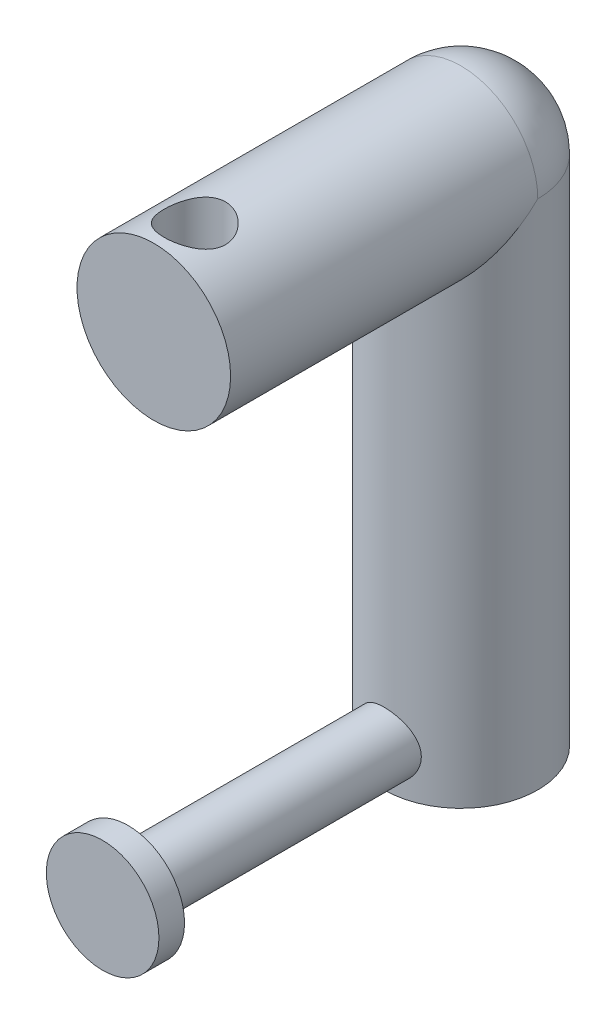
from build123d import *

# Parameters (mm, degrees)
SKETCH1_R                            = 15
BOSS_EXTRUDE1_DEPTH                  = 100
SKETCH2_R                            = 6
BOSS_EXTRUDE2_DEPTH                  = 50
BOSS_EXTRUDE2_DIRECTION_2_REACH      = 107.475
BOSS_EXTRUDE2_DIRECTION_2_END_RADIUS = 15
REVOLVE1_ANGLE                       = 180
SKETCH4_R                            = 15
BOSS_EXTRUDE3_DEPTH                  = 60
SKETCH5_R                            = 6
CUT_EXTRUDE1_DEPTH                   = 30
SKETCH6_R                            = 11
BOSS_EXTRUDE4_DEPTH                  = 5


with BuildPart() as part:
    # Sketch1 → Boss-Extrude1 (new body)
    with BuildSketch(Plane(origin=(0, 0, 0), x_dir=(1, 0, 0), z_dir=(0, 1, 0))):
        with Locations(Location((0, 0, 0), (0, 0, 270))):
            Circle(SKETCH1_R)
    extrude(amount=BOSS_EXTRUDE1_DEPTH)

    # Sketch3 → Revolve1 (revolve)
    with BuildSketch(Plane.XY):
        with BuildLine():
            Line((0, 100), (0, 115))
            ThreePointArc((0, 115), (-10.606601718, 110.606601718), (-15, 100))
            Line((-15, 100), (0, 100))
        make_face()
    revolve(axis=Axis((0, 100, 0), (0, -1, 0)), revolution_arc=REVOLVE1_ANGLE)

    # Sketch4 → Boss-Extrude3 (add)
    with BuildSketch(Plane.XY):
        with Locations((0, 100)):
            Circle(SKETCH4_R)
    extrude(amount=BOSS_EXTRUDE3_DEPTH)

    # Sketch5 → Cut-Extrude1 (cut)
    with BuildSketch(Plane(origin=(0, 115, 0), x_dir=(1, 0, 0), z_dir=(0, 1, 0))):
        with Locations(Location((0, -52, 0), (0, 0, 270))):
            Circle(SKETCH5_R)
    extrude(amount=-CUT_EXTRUDE1_DEPTH, mode=Mode.SUBTRACT)


with BuildPart() as body_2:
    # Sketch2 → Boss-Extrude2 (new body)
    with BuildSketch(Plane.XY.offset(15)):
        with Locations((0, 8)):
            Circle(SKETCH2_R)
    extrude(amount=BOSS_EXTRUDE2_DEPTH)

    # Boss-Extrude2 direction 2: up to this cylinder (the profile starts outside it)
    boss_extrude2_direction_2_end = Plane(origin=(0, 8, 0), z_dir=(0, -1, 0)) * Cylinder(BOSS_EXTRUDE2_DIRECTION_2_END_RADIUS, 245.95, mode=Mode.PRIVATE)
    # Sketch2 → Boss-Extrude2 direction 2 (add, up to the surface)
    with BuildSketch(Plane.XY.offset(15), mode=Mode.PRIVATE) as boss_extrude2_direction_2_sk1:
        with Locations((0, 8)):
            Circle(SKETCH2_R)
    boss_extrude2_direction_2_tool1 = extrude(boss_extrude2_direction_2_sk1.sketch, amount=-BOSS_EXTRUDE2_DIRECTION_2_REACH, mode=Mode.PRIVATE) - boss_extrude2_direction_2_end
    add(boss_extrude2_direction_2_tool1.solids().sort_by_distance((0, 8, 15))[0])
    add(boss_extrude2_direction_2_tool1.solids().sort_by_distance((0, 8, 15))[1])

    # Sketch6 → Boss-Extrude4 (add)
    with BuildSketch(Plane.XY.offset(65)):
        with Locations((0, 8)):
            Circle(SKETCH6_R)
    extrude(amount=BOSS_EXTRUDE4_DEPTH)


solid = Compound([part.part, body_2.part])
